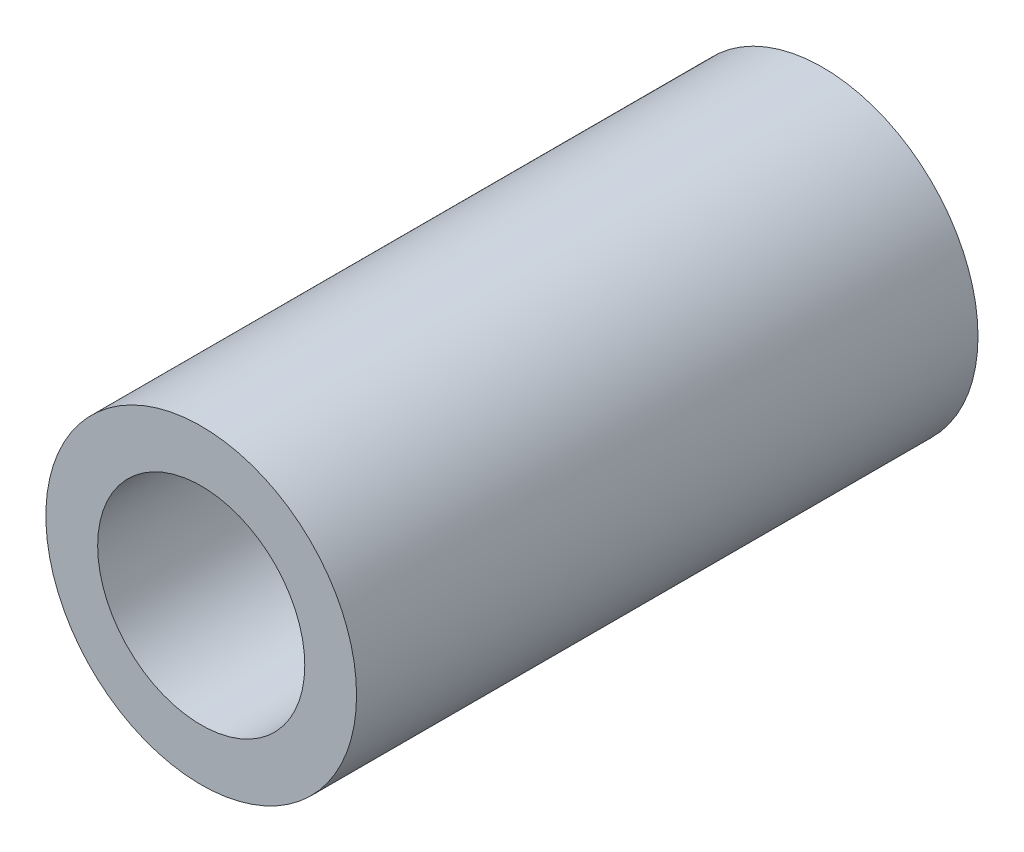
from build123d import *

# Parameters (mm, degrees)
ESQUISSE2_R        = 15
ESQUISSE2_R_2      = 10
BOSS_EXTRU_1_DEPTH = 60


with BuildPart() as part:
    # Esquisse2 → Boss.-Extru.1 (new body)
    with BuildSketch(Plane.XY):
        Circle(ESQUISSE2_R)
        Circle(ESQUISSE2_R_2, mode=Mode.SUBTRACT)
    extrude(amount=BOSS_EXTRU_1_DEPTH)


solid = part.part
